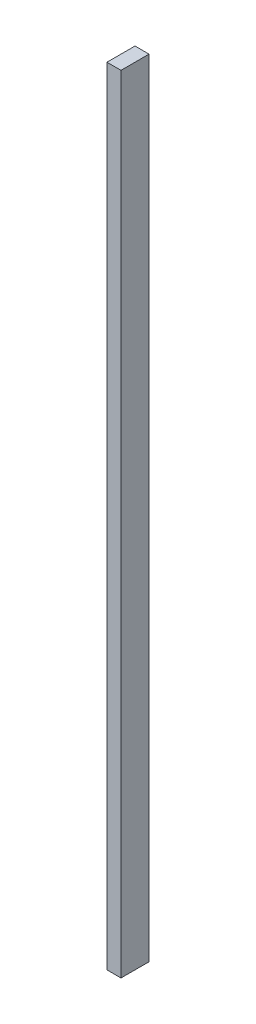
from build123d import *

# Parameters (mm, degrees)
SKETCH2_W           = 1
SKETCH2_H           = 2
BOSS_EXTRUDE2_DEPTH = 56


with BuildPart() as part:
    # Sketch2 → Boss-Extrude2 (new body)
    with BuildSketch(Plane(origin=(0, 0, 0), x_dir=(-1, 0, 0), z_dir=(0, -1, 0))):
        with Locations((-0.5, 1)):
            Rectangle(SKETCH2_W, SKETCH2_H)
    extrude(amount=-BOSS_EXTRUDE2_DEPTH)


solid = part.part
